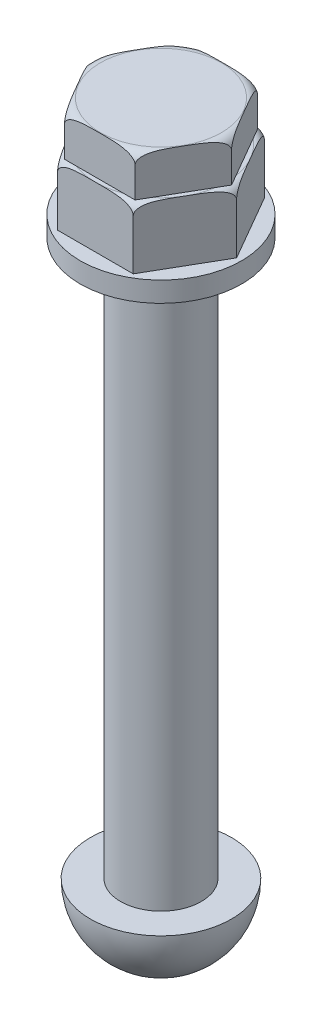
from build123d import *

# Parameters (mm, degrees)
SKETCH2_R           = 16
BOSS_EXTRUDE1_DEPTH = 4
BOSS_EXTRUDE2_DEPTH = 12
BOSS_EXTRUDE3_DEPTH = 8


with BuildPart() as part:
    # Sketch1 → Revolve1 (revolve)
    with BuildSketch(Plane.XY):
        with BuildLine():
            Line((0, 45), (0, -79))
            ThreePointArc((0, -79), (9.899494937, -74.899494937), (14, -65))
            Line((14, -65), (8, -65))
            Line((8, -65), (8, 45))
            Line((8, 45), (0, 45))
        make_face()
    revolve(axis=Axis((0, 45, 0), (0, -1, 0)))

    # Sketch2 → Boss-Extrude1 (add)
    with BuildSketch(Plane(origin=(0, 45, 0), x_dir=(1, 0, 0), z_dir=(0, 1, 0))):
        Circle(SKETCH2_R)
    extrude(amount=BOSS_EXTRUDE1_DEPTH)

    # Sketch3 → Boss-Extrude2 (add)
    with BuildSketch(Plane(origin=(0, 49, 0), x_dir=(1, 0, 0), z_dir=(0, 1, 0))):
        Polygon((15, 0), (7.5, 12.990381057), (-7.5, 12.990381057), (-15, 0), (-7.5, -12.990381057), (7.5, -12.990381057), align=None)
    extrude(amount=BOSS_EXTRUDE2_DEPTH)

    # Sketch4 → Cut-Revolve1 (revolve, cut)
    with BuildSketch(Plane.XY):
        with BuildLine():
            Line((-11.25, 61), (-11.845920892, 86.206852949))
            Line((-11.845920892, 86.206852949), (-19.210159843, 81.730550841))
            Line((-19.210159843, 81.730550841), (-15, 77.218149523))
            Line((-15, 77.218149523), (-15, 59))
            ThreePointArc((-15, 59), (-14.414213562, 60.414213562), (-13, 61))
            Line((-13, 61), (-11.25, 61))
        make_face()
    revolve(axis=Axis((0, 61, 0), (0, 1, 0)), mode=Mode.SUBTRACT)

    # Sketch5 → Boss-Extrude3 (add)
    with BuildSketch(Plane(origin=(0, 61, 0), x_dir=(1, 0, 0), z_dir=(0, 1, 0))):
        Polygon((14, 0), (7, 12.124355653), (-7, 12.124355653), (-14, 0), (-7, -12.124355653), (7, -12.124355653), align=None)
    extrude(amount=BOSS_EXTRUDE3_DEPTH)

    # Sketch7 → Cut-Revolve4 (revolve, cut)
    with BuildSketch(Plane.XY):
        with BuildLine():
            Line((-10.420461745, 69), (-11.491114181, 93.356215437))
            Line((-11.491114181, 93.356215437), (-17.705025471, 88.394162347))
            Line((-17.705025471, 88.394162347), (-14, 85.377305621))
            Line((-14, 85.377305621), (-14, 67))
            ThreePointArc((-14, 67), (-13.414213562, 68.414213562), (-12, 69))
            Line((-12, 69), (-10.420461745, 69))
        make_face()
    revolve(axis=Axis((0, 69, 0), (0, 1, 0)), mode=Mode.SUBTRACT)


solid = part.part
